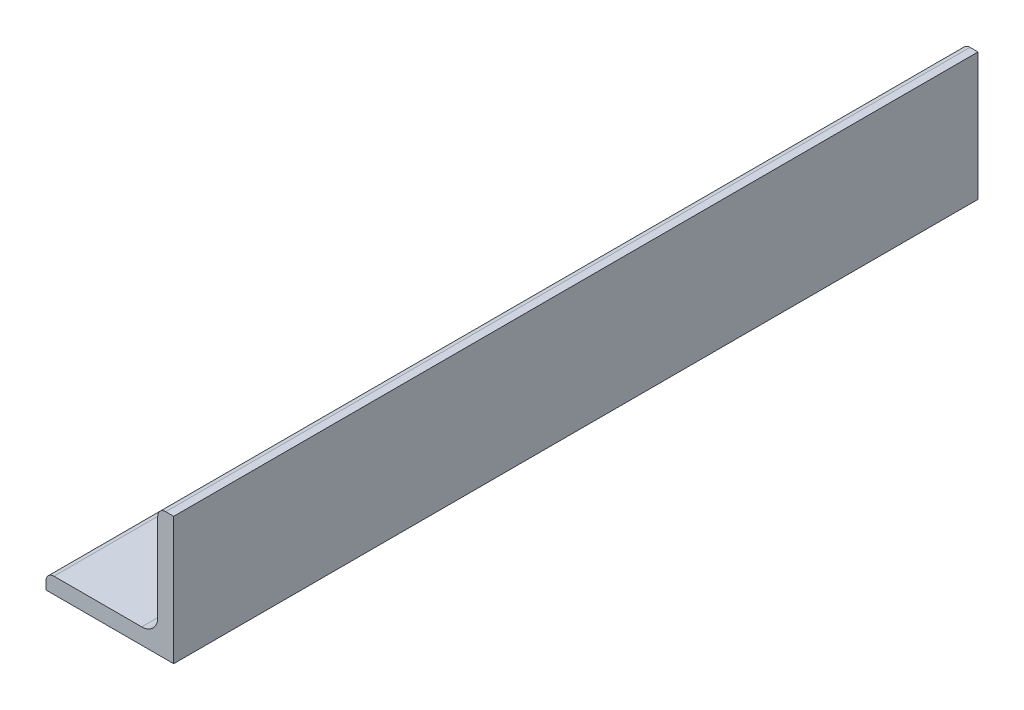
from build123d import *

# Parameters (mm, degrees)
BOSS_EXTRUDE1_DEPTH = 609.6
SKETCH3_W           = 1059.2
SKETCH3_H           = 25.4
CUT_EXTRUDE2_DEPTH  = 30.48


with BuildPart() as part:
    # Sketch2 → Boss-Extrude1 (new, symmetric)
    with BuildSketch(Plane.XY):
        with BuildLine():
            Line((-12.7, -12.7), (12.7, -12.7))
            Line((12.7, -12.7), (12.7, 12.7))
            Line((12.7, 12.7), (11.1125, 12.7))
            ThreePointArc((11.1125, 12.7), (9.989967985, 12.235032015), (9.525, 11.1125))
            Line((9.525, 11.1125), (9.525, -6.35))
            ThreePointArc((9.525, -6.35), (8.59506403, -8.59506403), (6.35, -9.525))
            Line((6.35, -9.525), (-11.1125, -9.525))
            ThreePointArc((-11.1125, -9.525), (-12.235032015, -9.989967985), (-12.7, -11.1125))
            Line((-12.7, -11.1125), (-12.7, -12.7))
        make_face()
    extrude(amount=BOSS_EXTRUDE1_DEPTH, both=True)

    # Sketch3 → Cut-Extrude2 (cut)
    with BuildSketch(Plane(origin=(12.7, 0, 0), x_dir=(0, 0, -1), z_dir=(1, 0, 0))):
        with Locations((80, 0)):
            Rectangle(SKETCH3_W, SKETCH3_H)
    extrude(amount=-CUT_EXTRUDE2_DEPTH, mode=Mode.SUBTRACT)


solid = part.part
